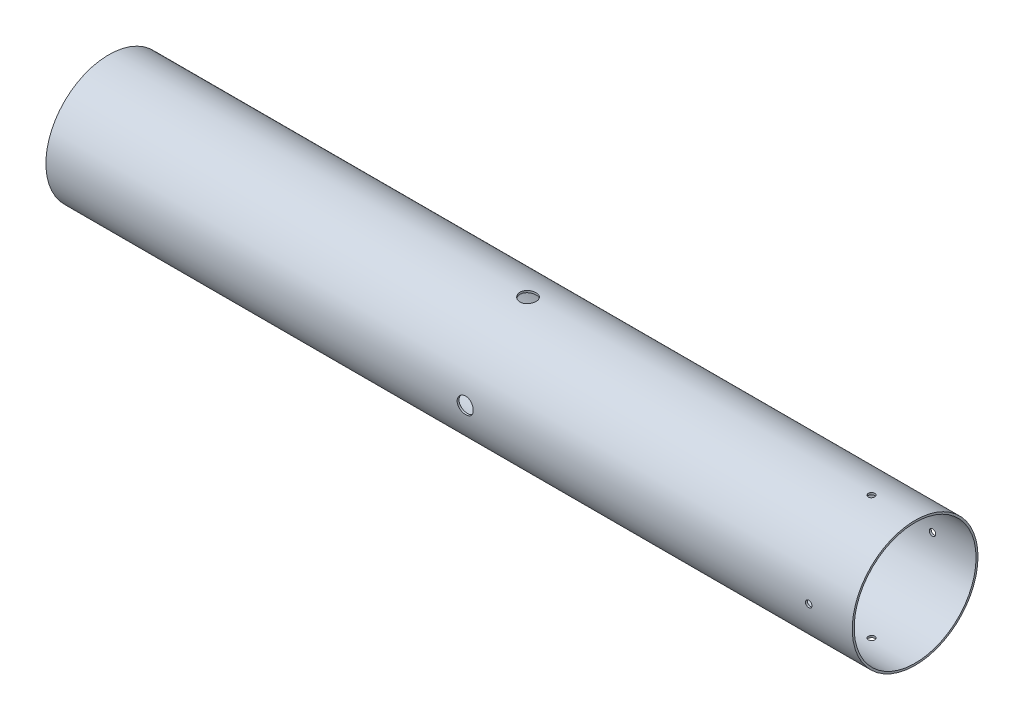
from build123d import *

# Parameters (mm, degrees)
CROQUIS1_R              = 38.99
CROQUIS1_R_2            = 37.79
SALIENTE_EXTRUIR1_DEPTH = 250
CROQUIS3_R              = 5
CORTAR_EXTRUIR1_DEPTH   = 39.99
MATRIZC4_COUNT          = 2
MATRIZC4_ANGLE          = 90
CROQUIS4_R              = 2
CORTAR_EXTRUIR2_DEPTH   = 39.9900001
MATRIZC5_COUNT          = 2
MATRIZC5_ANGLE          = 90


with BuildPart() as part:
    # Croquis1 → Saliente-Extruir1 (new body, symmetric)
    with BuildSketch(Plane(origin=(0, 0, 0), x_dir=(0, 0, -1), z_dir=(1, 0, 0))):
        Circle(CROQUIS1_R)
        Circle(CROQUIS1_R_2, mode=Mode.SUBTRACT)
    extrude(amount=SALIENTE_EXTRUIR1_DEPTH, both=True)

    # Croquis3 → Cortar-Extruir1 (cut, symmetric)
    with BuildSketch(Plane.XY):
        with Locations((10, 0)):
            Circle(CROQUIS3_R)
    cortar_extruir1 = extrude(amount=CORTAR_EXTRUIR1_DEPTH, both=True, mode=Mode.SUBTRACT)

    # MatrizC4: Cortar-Extruir1 ×2 about axis
    matrizc4_axis = Axis((250, 0, 0), (1, 0, 0))
    for i in range(1, MATRIZC4_COUNT):
        add(cortar_extruir1.rotate(matrizc4_axis, i * MATRIZC4_ANGLE / (MATRIZC4_COUNT - 1)), mode=Mode.SUBTRACT)

    # Croquis4 → Cortar-Extruir2 (cut, symmetric)
    with BuildSketch(Plane.XY):
        with Locations((223, 0)):
            Circle(CROQUIS4_R)
    cortar_extruir2 = extrude(amount=CORTAR_EXTRUIR2_DEPTH, both=True, mode=Mode.SUBTRACT)

    # MatrizC5: Cortar-Extruir2 ×2 about axis
    matrizc5_axis = Axis((250, 0, 0), (1, 0, 0))
    for i in range(1, MATRIZC5_COUNT):
        add(cortar_extruir2.rotate(matrizc5_axis, i * MATRIZC5_ANGLE / (MATRIZC5_COUNT - 1)), mode=Mode.SUBTRACT)


solid = part.part
